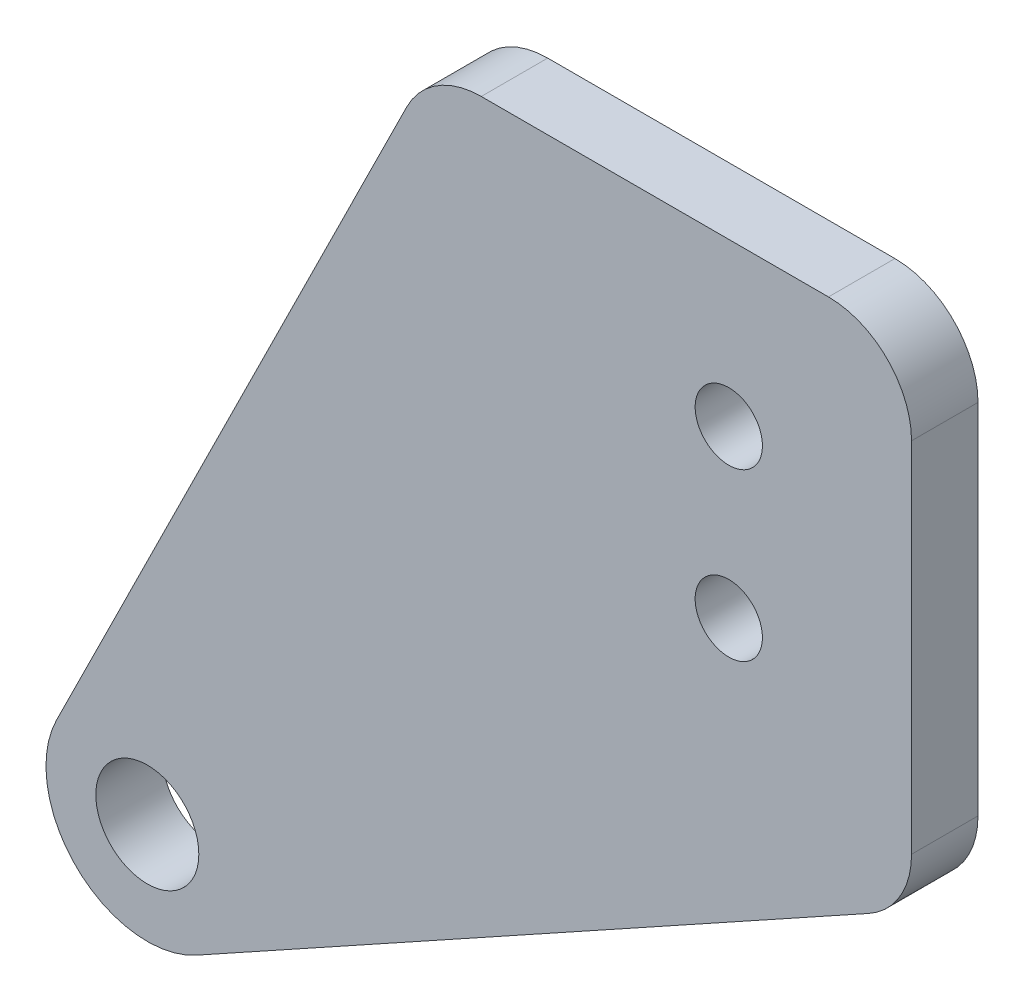
from build123d import *

# Parameters (mm, degrees)
SKETCH_2_R      = 2.025
SKETCH_2_R_2    = 3.1
EXTRUDE_1_DEPTH = 4
FILLET_1_R      = 5


with BuildPart() as part:
    # 草图2 → 凸台-拉伸1 (new body)
    with BuildSketch(Plane.XY):
        with BuildLine():
            Line((-22, 14.75), (-44.464667105, -30.539388734))
            ThreePointArc((-44.464667105, -30.539388734), (-43.214642655, -37.659851164), (-36.044914585, -38.586428599))
            Line((-36.044914585, -38.586428599), (7, -14.75))
            Line((7, -14.75), (7, 14.75))
            Line((7, 14.75), (-22, 14.75))
        make_face()
        with Locations((-4, 5)):
            Circle(SKETCH_2_R, mode=Mode.SUBTRACT)
        with Locations((-4, -5)):
            Circle(SKETCH_2_R, mode=Mode.SUBTRACT)
        with Locations((-39, -33.25)):
            Circle(SKETCH_2_R_2, mode=Mode.SUBTRACT)
    extrude(amount=EXTRUDE_1_DEPTH)

    # 圆角1
    fillet_1_edges = [part.edges().sort_by_distance(p)[0] for p in [
        (-22, 14.75, 2),
        (7, 14.75, 2),
        (7, -14.75, 2),
    ]]
    fillet(fillet_1_edges, radius=FILLET_1_R)


solid = part.part
